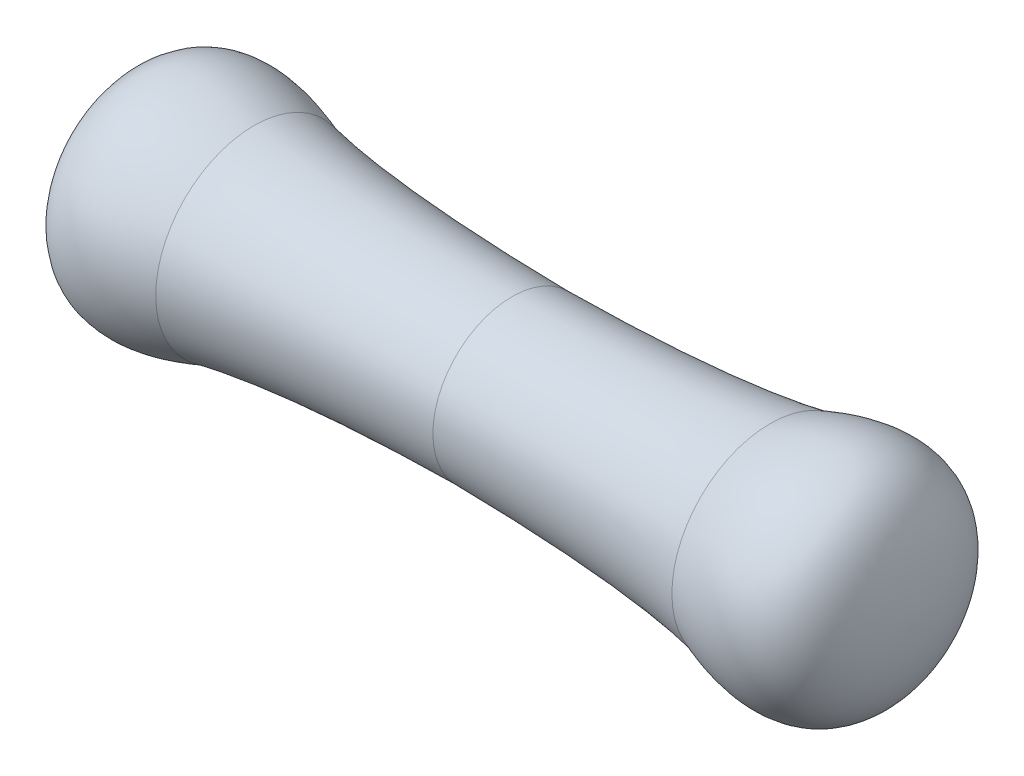
from build123d import *


with BuildPart() as part:
    # Esquisse1 → Révolution1 (revolve)
    with BuildSketch(Plane.XY):
        with BuildLine():
            Line((-3.5, 0), (3.5, 0))
            add(Edge.make_bspline(
                [(3.5, 0), (3.467480709, 1.317478191), (2.245790229, 0.85441809)],
                knots=[0, 0, 0, 1, 1, 1], degree=2))
            add(Edge.make_bspline(
                [(2.245790229, 0.85441809), (1.507271151, 0.704582097), (0, 0.688368718)],
                knots=[0, 0, 0, 1, 1, 1], degree=2))
            add(Edge.make_bspline(
                [(-2.245790229, 0.85441809), (-1.507271151, 0.704582097), (0, 0.688368718)],
                knots=[0, 0, 0, 1, 1, 1], degree=2))
            add(Edge.make_bspline(
                [(-3.5, 0), (-3.467480709, 1.317478191), (-2.245790229, 0.85441809)],
                knots=[0, 0, 0, 1, 1, 1], degree=2))
        make_face()
    revolve(axis=Axis((-3.5, 0, 0), (1, 0, 0)))


solid = part.part
